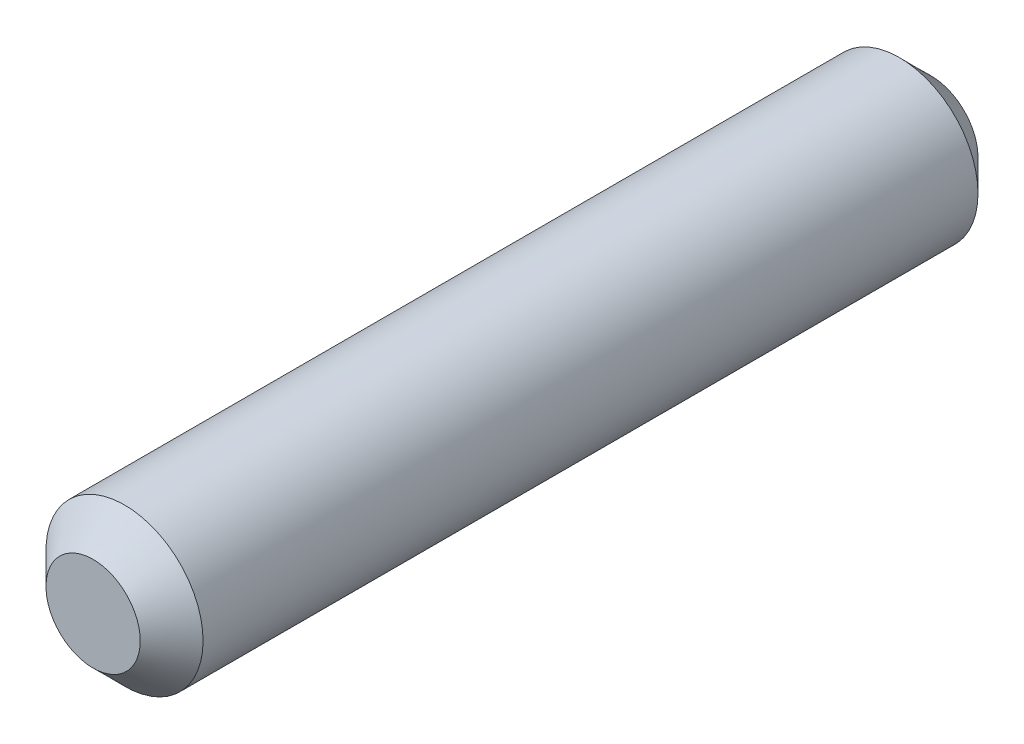
from build123d import *

# Parameters (mm, degrees)
SKETCH1_R           = 1.5
BOSS_EXTRUDE1_DEPTH = 16
CHAMFER1_SIZE       = 0.6


with BuildPart() as part:
    # Sketch1 → Boss-Extrude1 (new body)
    with BuildSketch(Plane.XY):
        Circle(SKETCH1_R)
    extrude(amount=BOSS_EXTRUDE1_DEPTH)

    # Chamfer1
    chamfer1_edges = [part.edges().sort_by_distance(p)[0] for p in [
        (-1.5, 0, 0),
        (-1.5, 0, 16),
    ]]
    chamfer(chamfer1_edges, length=CHAMFER1_SIZE)


solid = part.part
